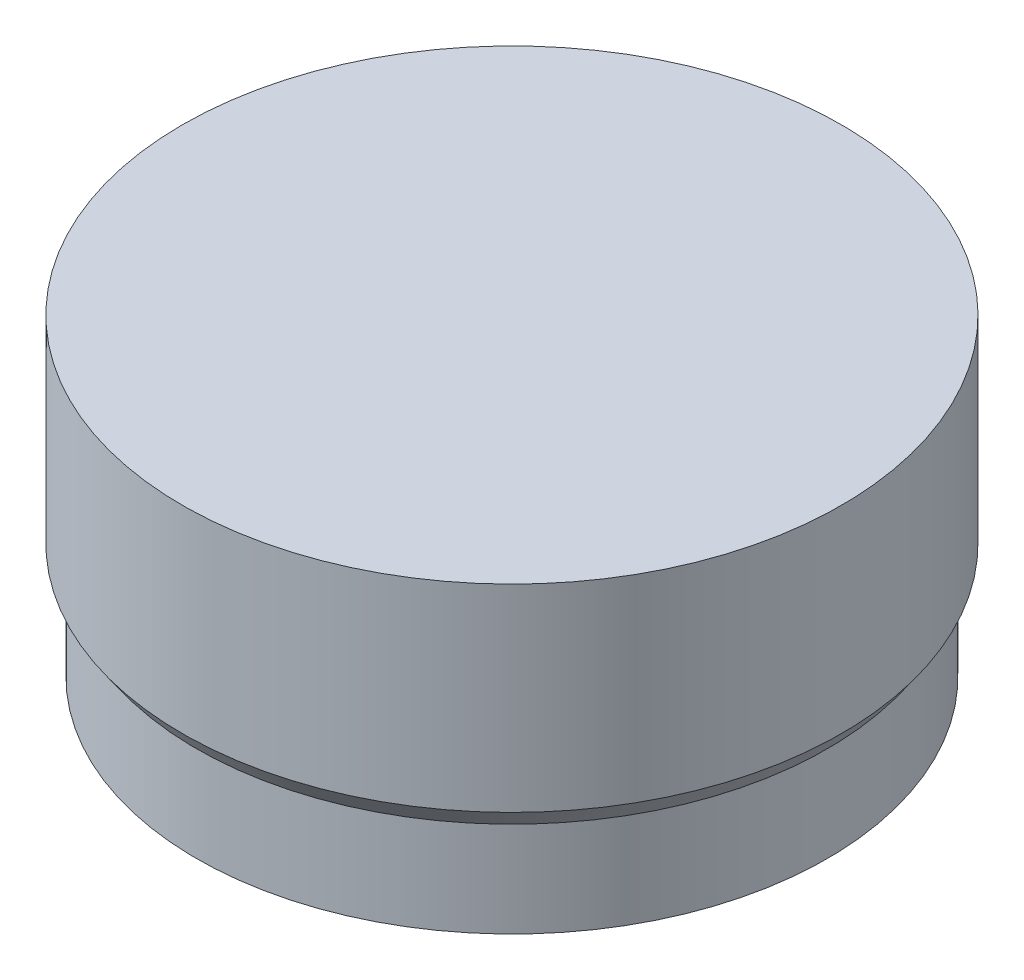
from build123d import *


with BuildPart() as part:
    # Sketch1 → Revolve1 (revolve)
    with BuildSketch(Plane.XY):
        Polygon((0, 0), (1.720729309, 2.457456133), (1.720729309, 26.457456133), (-0.679270691, 26.457456133), (-38.279270691, 26.457456133), (-38.279270691, -11.542543867), (0, -11.542543867), align=None)
    revolve(axis=Axis((-38.279270691, 29.419002817, 0), (0, -1, 0)))


solid = part.part
